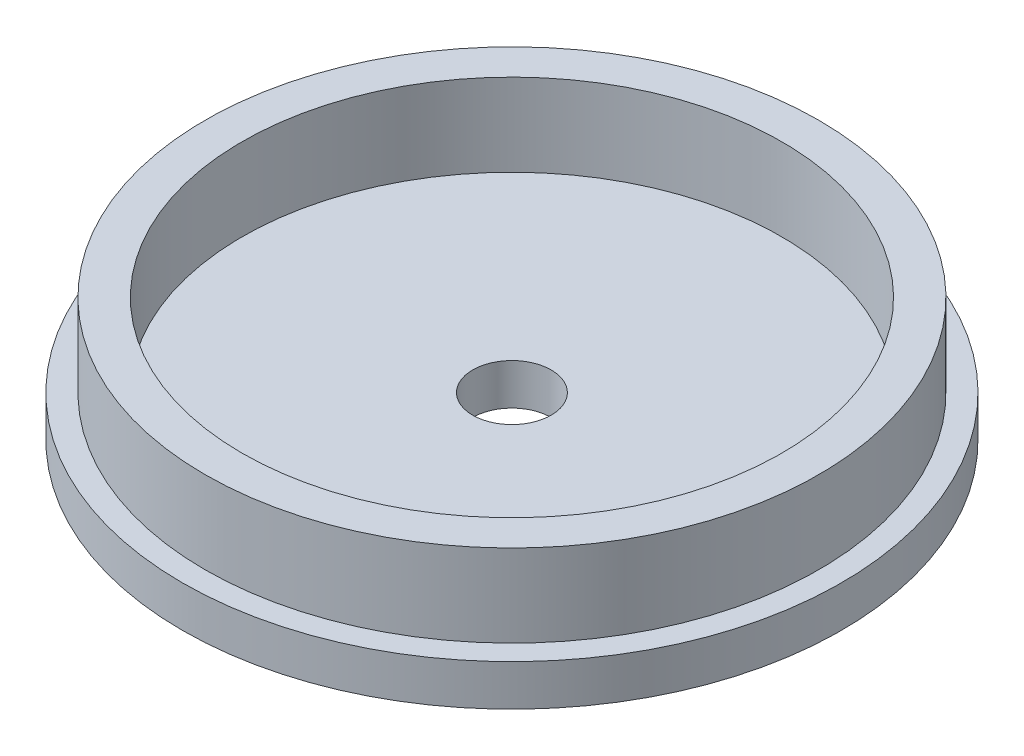
from build123d import *

# Parameters (mm, degrees)
SKETCH1_R           = 40
BOSS_EXTRUDE1_DEPTH = 5
SKETCH1_4_R         = 37.25
BOSS_EXTRUDE2_DEPTH = 10
SKETCH6_R           = 32.750011187
CUT_EXTRUDE1_DEPTH  = 10
SKETCH7_R           = 4.7625
CUT_EXTRUDE2_DEPTH  = 10


with BuildPart() as part:
    # Sketch1 → Boss-Extrude1 (new body)
    with BuildSketch(Plane(origin=(0, 0, 0), x_dir=(1, 0, 0), z_dir=(0, 1, 0))):
        Circle(SKETCH1_R)
    extrude(amount=-BOSS_EXTRUDE1_DEPTH)

    # Sketch1_4 → Boss-Extrude2 (add)
    with BuildSketch(Plane(origin=(0, 0, 0), x_dir=(1, 0, 0), z_dir=(0, 1, 0))):
        Circle(SKETCH1_4_R)
    extrude(amount=BOSS_EXTRUDE2_DEPTH)

    # Sketch6 → Cut-Extrude1 (cut)
    with BuildSketch(Plane(origin=(0, 10, 0), x_dir=(1, 0, 0), z_dir=(0, 1, 0))):
        Circle(SKETCH6_R)
    extrude(amount=-CUT_EXTRUDE1_DEPTH, mode=Mode.SUBTRACT)

    # Sketch7 → Cut-Extrude2 (cut)
    with BuildSketch(Plane(origin=(0, 0, 0), x_dir=(1, 0, 0), z_dir=(0, 1, 0))):
        Circle(SKETCH7_R)
    extrude(amount=-CUT_EXTRUDE2_DEPTH, mode=Mode.SUBTRACT)


solid = part.part
